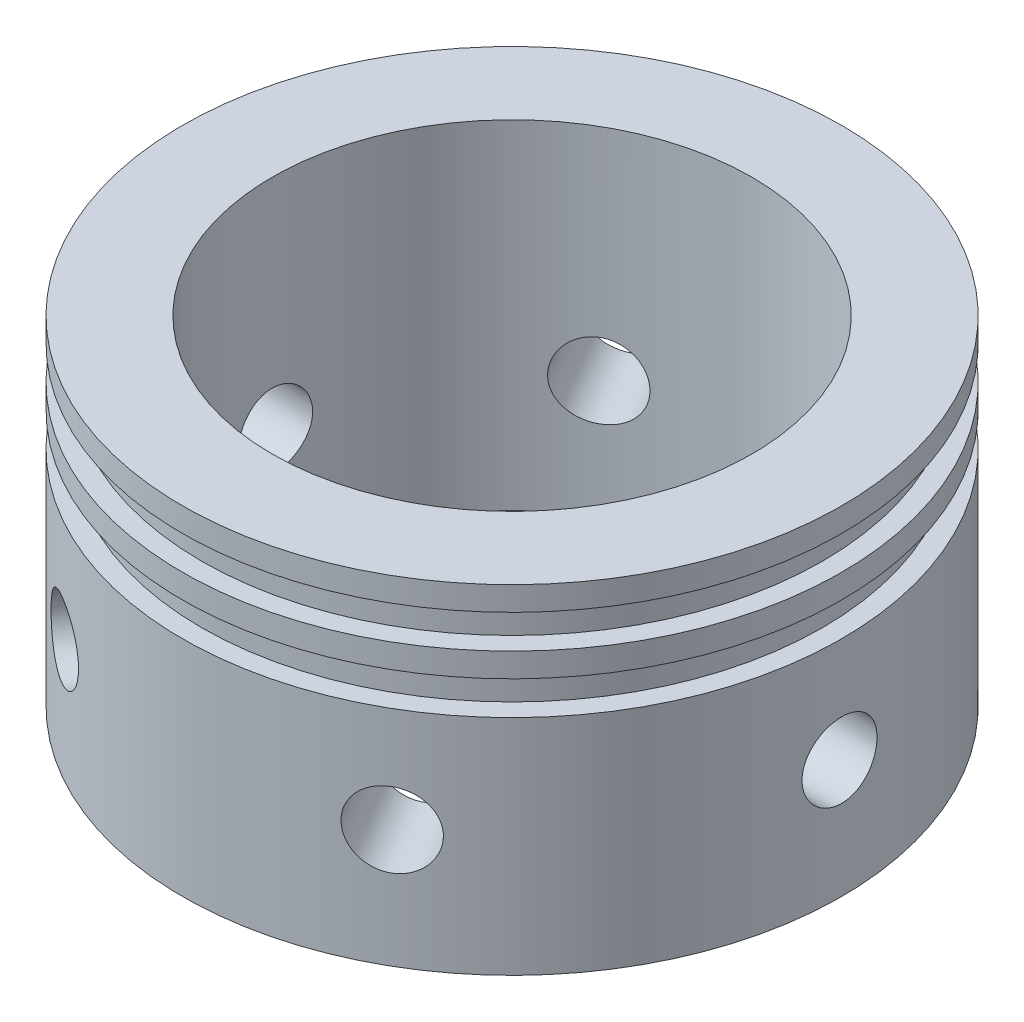
from build123d import *

# Parameters (mm, degrees)
F_3_8_16_TAPPED_HOLE2_REACH  = 90.009
F_3_8_16_TAPPED_HOLE2_BORE_R = 3.96875
CIRPATTERN1_COUNT            = 6


with BuildPart() as part:
    # Sketch2 → Revolve1 (revolve)
    with BuildSketch(Plane.XY, mode=Mode.PRIVATE) as revolve1_sk:
        Polygon((-34.8996, 40.689305596), (-25.4, 40.689305596), (-25.4, 4.857627196), (-34.8996, 4.857627196), (-34.8996, 28.497305596), (-32.8676, 28.497305596), (-32.8676, 32.053305596), (-34.8996, 32.053305596), (-34.8996, 34.593305596), (-32.8676, 34.593305596), (-32.8676, 38.149305596), (-34.8996, 38.149305596), align=None)
    revolve(revolve1_sk.sketch.rotate(Axis((0, 0, 0), (0, 1, 0)), 270), axis=Axis((0, 0, 0), (0, 1, 0)))

    # 3_8-16 Tapped Hole2 bore → 3_8-16 Tapped Hole2 (cut, up to next)
    with BuildSketch(Plane(origin=(34.8996, 0, 0), x_dir=(0, 0, -1), z_dir=(1, 0, 0)), mode=Mode.PRIVATE) as f_3_8_16_tapped_hole2_sk1:
        with Locations((0, 17.372080196)):
            Circle(F_3_8_16_TAPPED_HOLE2_BORE_R)
    f_3_8_16_tapped_hole2_tool1 = extrude(f_3_8_16_tapped_hole2_sk1.sketch, amount=-F_3_8_16_TAPPED_HOLE2_REACH, mode=Mode.PRIVATE) & part.part
    f_3_8_16_tapped_hole2 = f_3_8_16_tapped_hole2_tool1.solids().sort_by_distance((34.8996, 17.37208, 0))[0]
    add(f_3_8_16_tapped_hole2, mode=Mode.SUBTRACT)

    # CirPattern1: 3_8-16 Tapped Hole2 ×6 about axis
    cirpattern1_axis = Axis((0, 40.689305596, 0), (0, -1, 0))
    for i in range(1, CIRPATTERN1_COUNT):
        add(f_3_8_16_tapped_hole2.rotate(cirpattern1_axis, i * 360 / CIRPATTERN1_COUNT), mode=Mode.SUBTRACT)


solid = part.part
